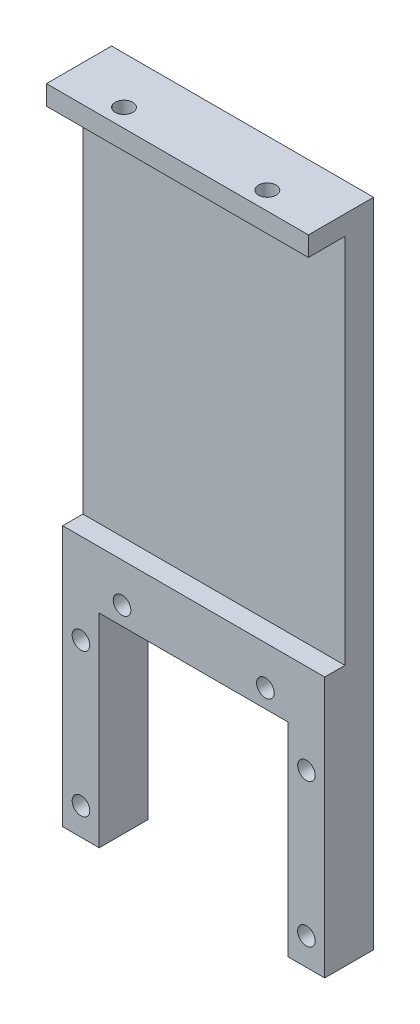
from build123d import *

# Parameters (mm, degrees)
SKETCH1_W           = 40.2
SKETCH1_H           = 100
BOSS_EXTRUDE1_DEPTH = 10
SKETCH7_W           = 40.2
SKETCH7_H           = 96.8
CUT_EXTRUDE5_DEPTH  = 2.5
SKETCH4_W           = 40.2
SKETCH4_H           = 57
CUT_EXTRUDE1_DEPTH  = 5.6
SKETCH3_W           = 29
SKETCH3_H           = 31.2
CUT_EXTRUDE2_DEPTH  = 11
SKETCH2_R           = 1.35
CUT_EXTRUDE3_DEPTH  = 11
CUT_EXTRUDE4_REACH  = 102
SKETCH6_R           = 1.35


with BuildPart() as part:
    # Sketch1 → Boss-Extrude1 (new body)
    with BuildSketch(Plane.XY):
        Rectangle(SKETCH1_W, SKETCH1_H)
    extrude(amount=BOSS_EXTRUDE1_DEPTH)

    # Sketch7 → Cut-Extrude5 (cut)
    with BuildSketch(Plane.XY.offset(10)):
        with Locations((0, -1.6)):
            Rectangle(SKETCH7_W, SKETCH7_H)
    extrude(amount=-CUT_EXTRUDE5_DEPTH, mode=Mode.SUBTRACT)

    # Sketch4 → Cut-Extrude1 (cut)
    with BuildSketch(Plane.XY.offset(10)):
        with Locations((0, 18.5)):
            Rectangle(SKETCH4_W, SKETCH4_H)
    extrude(amount=-CUT_EXTRUDE1_DEPTH, mode=Mode.SUBTRACT)

    # Sketch3 → Cut-Extrude2 (cut, through all)
    with BuildSketch(Plane.XY.offset(10)):
        with Locations((0, -34.4)):
            Rectangle(SKETCH3_W, SKETCH3_H)
    extrude(amount=-CUT_EXTRUDE2_DEPTH, mode=Mode.SUBTRACT)

    # Sketch2 → Cut-Extrude3 (cut, through all)
    with BuildSketch(Plane.XY.offset(10)):
        with Locations((17.3, -23.8)):
            Circle(SKETCH2_R)
        with Locations((11, -16)):
            Circle(SKETCH2_R)
        with Locations((-17.3, -23.8)):
            Circle(SKETCH2_R)
        with Locations((-11, -16)):
            Circle(SKETCH2_R)
        with Locations((-17.3, -45.8)):
            Circle(SKETCH2_R)
        with Locations((17.3, -45.8)):
            Circle(SKETCH2_R)
    extrude(amount=-CUT_EXTRUDE3_DEPTH, mode=Mode.SUBTRACT)

    # Sketch6 → Cut-Extrude4 (cut, up to next)
    with BuildSketch(Plane(origin=(0, 50, 0), x_dir=(-1, 0, 0), z_dir=(0, 1, 0)), mode=Mode.PRIVATE) as cut_extrude4_sk1:
        with Locations((-11, 7.2)):
            Circle(SKETCH6_R)
    cut_extrude4_tool1 = extrude(cut_extrude4_sk1.sketch, amount=-CUT_EXTRUDE4_REACH, mode=Mode.PRIVATE) & part.part
    add(cut_extrude4_tool1.solids().sort_by_distance((11, 50, 7.2))[0], mode=Mode.SUBTRACT)
    # Sketch6 → Cut-Extrude4 (cut, up to next)
    with BuildSketch(Plane(origin=(0, 50, 0), x_dir=(-1, 0, 0), z_dir=(0, 1, 0)), mode=Mode.PRIVATE) as cut_extrude4_sk2:
        with Locations((11, 7.2)):
            Circle(SKETCH6_R)
    cut_extrude4_tool2 = extrude(cut_extrude4_sk2.sketch, amount=-CUT_EXTRUDE4_REACH, mode=Mode.PRIVATE) & part.part
    add(cut_extrude4_tool2.solids().sort_by_distance((-11, 50, 7.2))[0], mode=Mode.SUBTRACT)


solid = part.part
